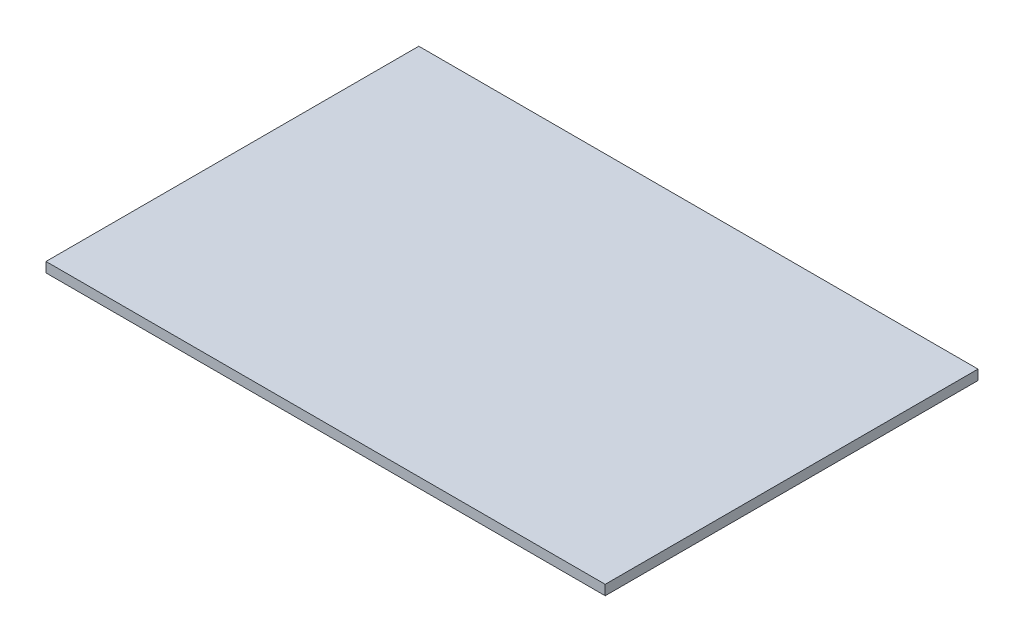
from build123d import *

# Parameters (mm, degrees)
SKETCH1_W           = 900
SKETCH1_H           = 600
BOSS_EXTRUDE1_DEPTH = 16


with BuildPart() as part:
    # Sketch1 → Boss-Extrude1 (new body)
    with BuildSketch(Plane(origin=(0, 0, 0), x_dir=(1, 0, 0), z_dir=(0, 1, 0))):
        Rectangle(SKETCH1_W, SKETCH1_H)
    extrude(amount=BOSS_EXTRUDE1_DEPTH)


solid = part.part
